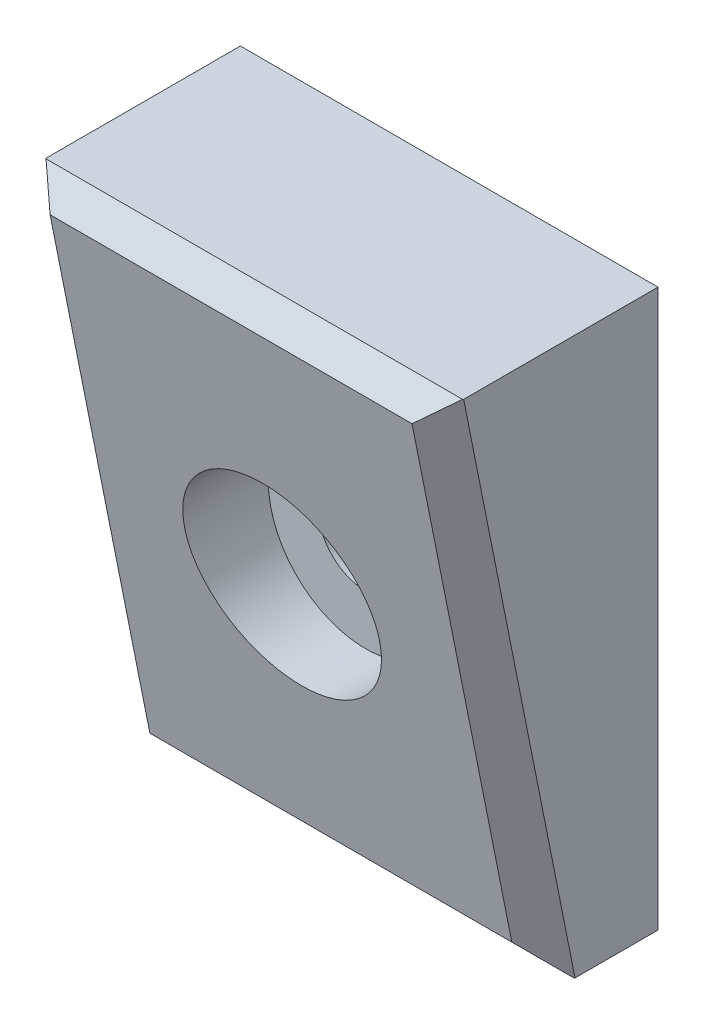
from build123d import *
from OCP.BRepFilletAPI import BRepFilletAPI_MakeChamfer

# Parameters (mm, degrees)
SKETCH1_W           = 15
SKETCH1_H           = 20
SKETCH1_R           = 1.7
BOSS_EXTRUDE1_DEPTH = 8
SKETCH2_R           = 3.5
CUT_EXTRUDE1_DEPTH  = 5
CUT_EXTRUDE2_DEPTH  = 20.723082923
CHAMFER1_SIZE       = 1
CHAMFER1_SIZE2      = 0.849836586
CHAMFER1_SIZE2_2    = 1.274754878


with BuildPart() as part:
    # Sketch1 → Boss-Extrude1 (new body)
    with BuildSketch(Plane.XY):
        Rectangle(SKETCH1_W, SKETCH1_H)
        Circle(SKETCH1_R, mode=Mode.SUBTRACT)
    extrude(amount=BOSS_EXTRUDE1_DEPTH)

    # Sketch2 → Cut-Extrude1 (cut)
    with BuildSketch(Plane.XY.offset(8)):
        Circle(SKETCH2_R)
    extrude(amount=-CUT_EXTRUDE1_DEPTH, mode=Mode.SUBTRACT)

    # Sketch3 → Cut-Extrude2 (cut, through all)
    with BuildSketch(Plane(origin=(7.5, 0, 0), x_dir=(0, 0, -1), z_dir=(1, 0, 0))):
        Polygon((-8, 10), (-4, -10), (-8, -10), align=None)
    extrude(amount=-CUT_EXTRUDE2_DEPTH, mode=Mode.SUBTRACT)

    # Chamfer1: one chamfer whose edges measure the first distance from different faces: ONE call of the kernel's chamfer builder (chamfer() names one face for all edges)
    chamfer1_edges_1 = [part.edges().sort_by_distance(p)[0] for p in [
        (0, 10, 8),
    ]]
    chamfer1_side_1 = [part.faces().sort_by_distance(p)[0] for p in [
        (0, 10, 4),
    ]]
    chamfer1_edges_2 = [part.edges().sort_by_distance(p)[0] for p in [
        (-7.5, 0, 6),
        (7.5, 0, 6),
    ]]
    chamfer1_edges_3 = [part.edges().sort_by_distance(p)[0] for p in [
        (0, -10, 4),
    ]]
    chamfer1_side_3 = [part.faces().sort_by_distance(p)[0] for p in [
        (0, -10, 2),
    ]]
    chamfer1 = BRepFilletAPI_MakeChamfer(part.part.solid().wrapped)
    for e in chamfer1_edges_1:
        chamfer1.Add(CHAMFER1_SIZE, CHAMFER1_SIZE2, e.wrapped, chamfer1_side_1[0].wrapped)  # the first distance lies on this face
    for e in chamfer1_edges_2:
        chamfer1.Add(CHAMFER1_SIZE, e.wrapped)
    for e in chamfer1_edges_3:
        chamfer1.Add(CHAMFER1_SIZE, CHAMFER1_SIZE2_2, e.wrapped, chamfer1_side_3[0].wrapped)  # the first distance lies on this face
    add(Compound.cast(chamfer1.Shape()), mode=Mode.REPLACE)


solid = part.part
